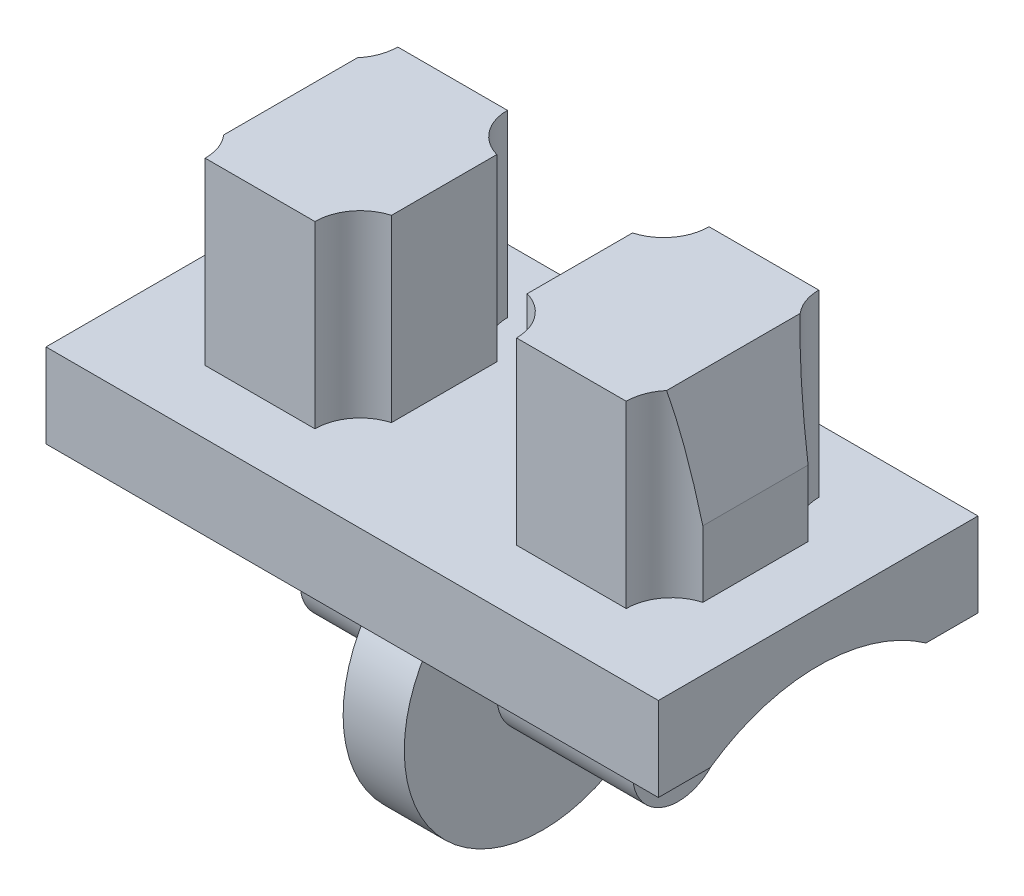
from build123d import *

# Parameters (mm, degrees)
EXTRUDE_1_DEPTH     = 0.775
SKETCH_2_R          = 1.155
EXTRUDE_2_DEPTH     = 4.215
EXTRUDE_3_DEPTH     = 7.76
EXTRUDE_4_DEPTH     = 4.55
CUT_EXTRUDE_1_DEPTH = 2.5


with BuildPart() as part:
    # 스케치1 → 보스-돌출1 (new body, symmetric)
    with BuildSketch(Plane(origin=(0, 0, 0), x_dir=(0, 0, -1), z_dir=(1, 0, 0))):
        with BuildLine():
            Line((-2.73, 2.732106893), (-2.73, 2.198209499))
            ThreePointArc((-2.73, 2.198209499), (0, -3.505), (2.73, 2.198209499))
            Line((2.73, 2.198209499), (2.73, 2.732106893))
            ThreePointArc((2.73, 2.732106893), (0, 3.595), (-2.73, 2.732106893))
        make_face()
    extrude(amount=EXTRUDE_1_DEPTH, both=True)

    # 스케치2 → 보스-돌출2 (add, symmetric)
    with BuildSketch(Plane(origin=(0, 0, 0), x_dir=(0, 0, -1), z_dir=(1, 0, 0))):
        Circle(SKETCH_2_R)
    extrude(amount=EXTRUDE_2_DEPTH, both=True)

    # 스케치3 → 보스-돌출3 (add, symmetric)
    with BuildSketch(Plane(origin=(0, 0, 0), x_dir=(0, 0, -1), z_dir=(1, 0, 0))):
        with BuildLine():
            Line((-4.05, 2.73), (-2.73, 2.73))
            Line((-2.73, 2.73), (-2.73, 2.732106893))
            ThreePointArc((-2.73, 2.732106893), (0, 3.595), (2.73, 2.732106893))
            Line((2.73, 2.732106893), (2.73, 2.73))
            Line((2.73, 2.73), (4.05, 2.73))
            Line((4.05, 2.73), (4.05, 4.86))
            Line((4.05, 4.86), (-4.05, 4.86))
            Line((-4.05, 4.86), (-4.05, 2.73))
        make_face()
    extrude(amount=EXTRUDE_3_DEPTH, both=True)

    # 스케치4 → 보스-돌출4 (add)
    with BuildSketch(Plane(origin=(0, 4.86, 0), x_dir=(1, 0, 0), z_dir=(0, 1, 0))):
        with BuildLine():
            Line((-2.555, -2.44), (-5.335, -2.44))
            ThreePointArc((-5.335, -2.44), (-5.567190107, -1.747089472), (-6.17, -1.333982369))
            Line((-6.17, -1.333982369), (-6.17, 1.333982369))
            ThreePointArc((-6.17, 1.333982369), (-5.567190107, 1.747089472), (-5.335, 2.44))
            Line((-5.335, 2.44), (-2.555, 2.44))
            ThreePointArc((-2.555, 2.44), (-2.322809893, 1.747089472), (-1.72, 1.333982369))
            Line((-1.72, 1.333982369), (-1.72, -1.333982369))
            ThreePointArc((-1.72, -1.333982369), (-2.322809893, -1.747089472), (-2.555, -2.44))
        make_face()
    extrude_4 = extrude(amount=EXTRUDE_4_DEPTH)

    # 스케치5 → 컷-돌출1 (cut, symmetric)
    with BuildSketch(Plane.XY):
        Polygon((-6.17, 6.54), (-5.611088771, 9.41), (-6.17, 9.41), align=None)
    cut_extrude_1 = extrude(amount=CUT_EXTRUDE_1_DEPTH, both=True, mode=Mode.SUBTRACT)

    # 대칭 복사1: 보스-돌출4, 컷-돌출1 across plane
    add(extrude_4.mirror(Plane(origin=(0, 0, 0), x_dir=(0, 0, 1), z_dir=(1, 0, 0))))
    add(cut_extrude_1.mirror(Plane(origin=(0, 0, 0), x_dir=(0, 0, 1), z_dir=(1, 0, 0))), mode=Mode.SUBTRACT)


solid = part.part
